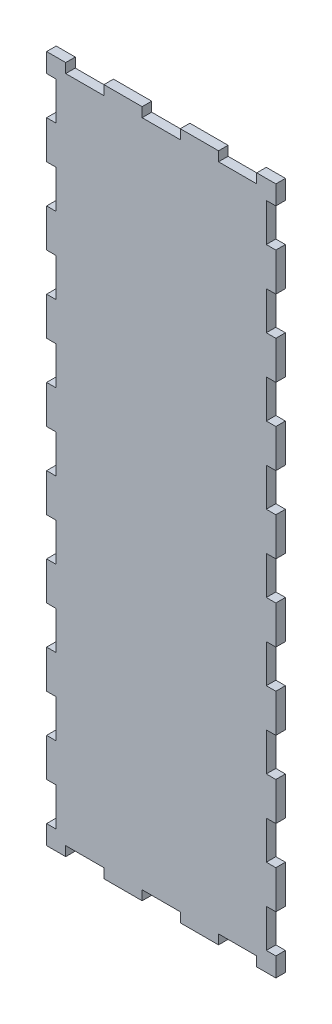
from build123d import *

# Parameters (mm, degrees)
SKETCH1_W            = 76.2
SKETCH1_H            = 228.6
EXTRUDE1_DEPTH       = 3.175
SKETCH3_W            = 3.175
SKETCH3_H            = 12.7
CUT_EXTRUDE1_DEPTH   = 3.175
LPATTERN1_COUNT      = 9
LPATTERN1_PITCH      = 25.4
LPATTERN1_COUNT_DIR2 = 2
LPATTERN1_PITCH_DIR2 = 73.025
SKETCH4_W            = 12.7
SKETCH4_H            = 3.175
CUT_EXTRUDE2_DEPTH   = 3.175
LPATTERN2_COUNT      = 3
LPATTERN2_PITCH      = 25.4
LPATTERN2_COUNT_DIR2 = 2
LPATTERN2_PITCH_DIR2 = 225.425


with BuildPart() as part:
    # Sketch1 → Extrude1 (new body)
    with BuildSketch(Plane.XY):
        with Locations((38.1, 114.3)):
            Rectangle(SKETCH1_W, SKETCH1_H)
    extrude(amount=EXTRUDE1_DEPTH)

    # Sketch3 → Cut-Extrude1 (cut)
    with BuildSketch(Plane.XY.offset(3.175)):
        with Locations((74.6125, 215.9)):
            Rectangle(SKETCH3_W, SKETCH3_H)
    cut_extrude1 = extrude(amount=-CUT_EXTRUDE1_DEPTH, mode=Mode.SUBTRACT)

    # LPattern1: Cut-Extrude1 9 × 2
    with Locations(*[(-j * LPATTERN1_PITCH_DIR2, -i * LPATTERN1_PITCH, 0) for i in range(LPATTERN1_COUNT) for j in range(LPATTERN1_COUNT_DIR2) if (i, j) != (0, 0)]):
        add(cut_extrude1, mode=Mode.SUBTRACT)

    # Sketch4 → Cut-Extrude2 (cut)
    with BuildSketch(Plane.XY.offset(3.175)):
        with Locations((63.5, 227.0125)):
            Rectangle(SKETCH4_W, SKETCH4_H)
    cut_extrude2 = extrude(amount=-CUT_EXTRUDE2_DEPTH, mode=Mode.SUBTRACT)

    # LPattern2: Cut-Extrude2 3 × 2
    with Locations(*[(-i * LPATTERN2_PITCH, -j * LPATTERN2_PITCH_DIR2, 0) for i in range(LPATTERN2_COUNT) for j in range(LPATTERN2_COUNT_DIR2) if (i, j) != (0, 0)]):
        add(cut_extrude2, mode=Mode.SUBTRACT)


solid = part.part
